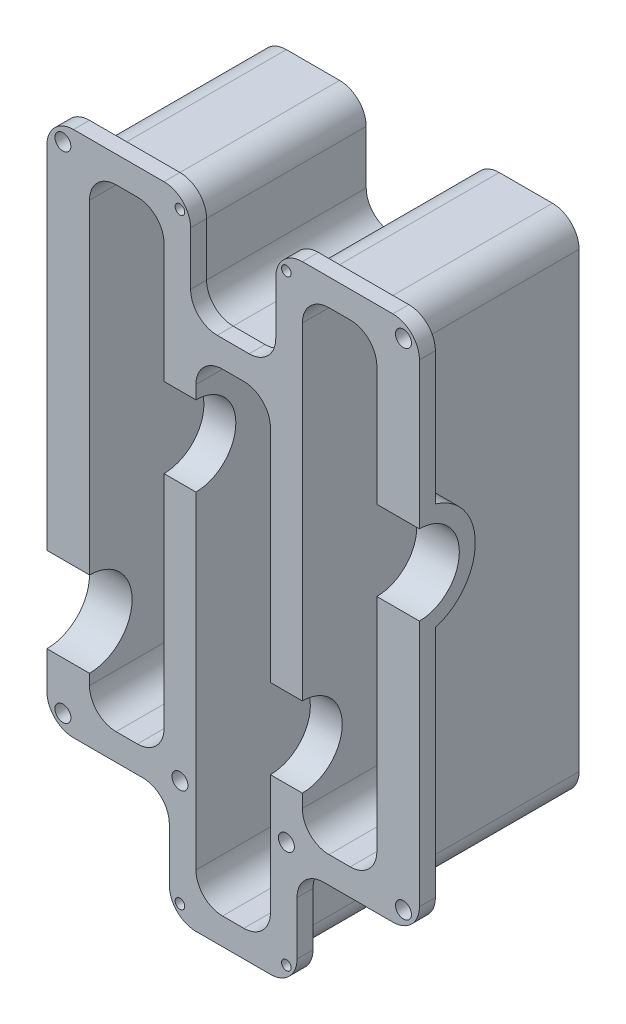
from build123d import *

# Parameters (mm, degrees)
SKETCH1_W           = 70
SKETCH1_H           = 119
BOSS_EXTRUDE1_DEPTH = 35
SKETCH2_R           = 8
CUT_EXTRUDE1_DEPTH  = 8
CUT_EXTRUDE2_DEPTH  = 32
SKETCH4_R           = 7.5
CUT_EXTRUDE3_DEPTH  = 8
SKETCH5_W           = 16
SKETCH5_H           = 20
SKETCH5_W_2         = 23
CUT_EXTRUDE4_DEPTH  = 36
CUT_EXTRUDE5_DEPTH  = 5
SKETCH7_W           = 18
SKETCH7_H           = 32
CUT_EXTRUDE6_DEPTH  = 2
SKETCH8_W           = 32
SKETCH8_H           = 22
CUT_EXTRUDE7_DEPTH  = 2
SKETCH9_W           = 22
SKETCH9_H           = 32
CUT_EXTRUDE8_DEPTH  = 2
SKETCH10_W          = 32
SKETCH10_H          = 18
CUT_EXTRUDE9_DEPTH  = 2
SKETCH11_W          = 25
SKETCH11_H          = 32
CUT_EXTRUDE10_DEPTH = 2
CUT_EXTRUDE11_DEPTH = 5
SKETCH14_W          = 22
SKETCH14_H          = 32
CUT_EXTRUDE12_DEPTH = 2
SKETCH16_W          = 32
SKETCH16_H          = 18
CUT_EXTRUDE13_DEPTH = 2
SKETCH17_W          = 18
SKETCH17_H          = 32
CUT_EXTRUDE14_DEPTH = 2
SKETCH18_W          = 32
SKETCH18_H          = 22
CUT_EXTRUDE15_DEPTH = 2
SKETCH19_W          = 20
SKETCH19_H          = 32
CUT_EXTRUDE16_DEPTH = 2
FILLET1_R           = 5
FILLET3_R           = 5
FILLET4_R           = 5
SKETCH20_R          = 1.5
CUT_EXTRUDE17_DEPTH = 10
SKETCH21_R          = 0.9
CUT_EXTRUDE18_DEPTH = 10
BOSS_EXTRUDE2_DEPTH = 6
BOSS_EXTRUDE3_DEPTH = 6


with BuildPart() as part:
    # Sketch1 → Boss-Extrude1 (new body)
    with BuildSketch(Plane.XY):
        Rectangle(SKETCH1_W, SKETCH1_H)
    extrude(amount=BOSS_EXTRUDE1_DEPTH)

    # Sketch2 → Cut-Extrude1 (cut)
    with BuildSketch(Plane.ZY.offset(35)):
        with Locations((35, -19.5)):
            Circle(SKETCH2_R)
    extrude(amount=-CUT_EXTRUDE1_DEPTH, mode=Mode.SUBTRACT)

    # Sketch3 → Cut-Extrude2 (cut)
    with BuildSketch(Plane.XY.offset(35)):
        Polygon((-27, 54.5), (-13, 54.5), (-13, 27), (-7, 27), (-7, 34.5), (7, 34.5), (7, -12), (13, -12), (13, 54.5), (27, 54.5), (27, -34.5), (13, -34.5), (13, -27), (7, -27), (7, -54.5), (-7, -54.5), (-7, 12), (-13, 12), (-13, -34.5), (-27, -34.5), align=None)
    extrude(amount=-CUT_EXTRUDE2_DEPTH, mode=Mode.SUBTRACT)

    # Sketch4 → Cut-Extrude3 (cut)
    with BuildSketch(Plane(origin=(35, 0, 0), x_dir=(0, 0, -1), z_dir=(1, 0, 0))):
        with Locations((-35, 19.5)):
            Circle(SKETCH4_R)
    extrude(amount=-CUT_EXTRUDE3_DEPTH, mode=Mode.SUBTRACT)

    # Sketch5 → Cut-Extrude4 (cut, through all)
    with BuildSketch(Plane.XY.offset(35)):
        with Locations((0, 49.5)):
            Rectangle(SKETCH5_W, SKETCH5_H)
        with Locations((-23.5, -49.5)):
            Rectangle(SKETCH5_W_2, SKETCH5_H)
        with Locations((23.5, -49.5)):
            Rectangle(SKETCH5_W_2, SKETCH5_H)
    extrude(amount=-CUT_EXTRUDE4_DEPTH, mode=Mode.SUBTRACT)

    # Sketch6 → Cut-Extrude5 (cut)
    with BuildSketch(Plane.ZY.offset(35)):
        with BuildLine():
            Line((32, 59.5), (0, 59.5))
            Line((0, 59.5), (0, -39.5))
            Line((0, -39.5), (32, -39.5))
            Line((32, -39.5), (32, -30.083005244))
            ThreePointArc((32, -30.083005244), (24, -19.5), (32, -8.916994756))
            Line((32, -8.916994756), (32, 59.5))
        make_face()
    extrude(amount=-CUT_EXTRUDE5_DEPTH, mode=Mode.SUBTRACT)

    # Sketch7 → Cut-Extrude6 (cut)
    with BuildSketch(Plane.XZ.offset(39.5)):
        with Locations((-21, 16)):
            Rectangle(SKETCH7_W, SKETCH7_H)
    extrude(amount=-CUT_EXTRUDE6_DEPTH, mode=Mode.SUBTRACT)

    # Sketch8 → Cut-Extrude7 (cut)
    with BuildSketch(Plane.ZY.offset(12)):
        with Locations((16, -48.5)):
            Rectangle(SKETCH8_W, SKETCH8_H)
    extrude(amount=-CUT_EXTRUDE7_DEPTH, mode=Mode.SUBTRACT)

    # Sketch9 → Cut-Extrude8 (cut)
    with BuildSketch(Plane.XZ.offset(59.5)):
        with Locations((1, 16)):
            Rectangle(SKETCH9_W, SKETCH9_H)
    extrude(amount=-CUT_EXTRUDE8_DEPTH, mode=Mode.SUBTRACT)

    # Sketch10 → Cut-Extrude9 (cut)
    with BuildSketch(Plane(origin=(12, 0, 0), x_dir=(0, 0, -1), z_dir=(1, 0, 0))):
        with Locations((-16, -48.5)):
            Rectangle(SKETCH10_W, SKETCH10_H)
    extrude(amount=-CUT_EXTRUDE9_DEPTH, mode=Mode.SUBTRACT)

    # Sketch11 → Cut-Extrude10 (cut)
    with BuildSketch(Plane.XZ.offset(39.5)):
        with Locations((22.5, 16)):
            Rectangle(SKETCH11_W, SKETCH11_H)
    extrude(amount=-CUT_EXTRUDE10_DEPTH, mode=Mode.SUBTRACT)

    # Sketch13 → Cut-Extrude11 (cut)
    with BuildSketch(Plane(origin=(35, 0, 0), x_dir=(0, 0, -1), z_dir=(1, 0, 0))):
        with BuildLine():
            Line((-32, 59.5), (0, 59.5))
            Line((0, 59.5), (0, -37.5))
            Line((0, -37.5), (-32, -37.5))
            Line((-32, -37.5), (-32, 9.437694101))
            ThreePointArc((-32, 9.437694101), (-24.5, 19.5), (-32, 29.562305899))
            Line((-32, 29.562305899), (-32, 59.5))
        make_face()
    extrude(amount=-CUT_EXTRUDE11_DEPTH, mode=Mode.SUBTRACT)

    # Sketch14 → Cut-Extrude12 (cut)
    with BuildSketch(Plane(origin=(0, 59.5, 0), x_dir=(1, 0, 0), z_dir=(0, 1, 0))):
        with Locations((19, -16)):
            Rectangle(SKETCH14_W, SKETCH14_H)
    extrude(amount=-CUT_EXTRUDE12_DEPTH, mode=Mode.SUBTRACT)

    # Sketch16 → Cut-Extrude13 (cut)
    with BuildSketch(Plane.ZY.offset(-8)):
        with Locations((16, 48.5)):
            Rectangle(SKETCH16_W, SKETCH16_H)
    extrude(amount=-CUT_EXTRUDE13_DEPTH, mode=Mode.SUBTRACT)

    # Sketch17 → Cut-Extrude14 (cut)
    with BuildSketch(Plane(origin=(0, 39.5, 0), x_dir=(1, 0, 0), z_dir=(0, 1, 0))):
        with Locations((1, -16)):
            Rectangle(SKETCH17_W, SKETCH17_H)
    extrude(amount=-CUT_EXTRUDE14_DEPTH, mode=Mode.SUBTRACT)

    # Sketch18 → Cut-Extrude15 (cut)
    with BuildSketch(Plane(origin=(-8, 0, 0), x_dir=(0, 0, -1), z_dir=(1, 0, 0))):
        with Locations((-16, 48.5)):
            Rectangle(SKETCH18_W, SKETCH18_H)
    extrude(amount=-CUT_EXTRUDE15_DEPTH, mode=Mode.SUBTRACT)

    # Sketch19 → Cut-Extrude16 (cut)
    with BuildSketch(Plane(origin=(0, 59.5, 0), x_dir=(1, 0, 0), z_dir=(0, 1, 0))):
        with Locations((-20, -16)):
            Rectangle(SKETCH19_W, SKETCH19_H)
    extrude(amount=-CUT_EXTRUDE16_DEPTH, mode=Mode.SUBTRACT)

    # Fillet1
    fillet1_edges = [part.edges().sort_by_distance(p)[0] for p in [
        (-27, -34.5, 19),
        (-27, 54.5, 19),
        (-13, 54.5, 19),
        (-7, 34.5, 19),
        (7, 34.5, 19),
        (13, 54.5, 19),
        (27, 54.5, 19),
        (27, -34.5, 19),
        (13, -34.5, 19),
        (7, -54.5, 19),
        (-7, -54.5, 19),
        (-13, -34.5, 19),
    ]]
    fillet(fillet1_edges, radius=FILLET1_R)

    # Fillet3
    fillet3_edges = [part.edges().sort_by_distance(p)[0] for p in [
        (-30, -37.5, 16),
        (-10, -37.5, 16),
        (-10, -57.5, 16),
        (10, -57.5, 16),
        (10, -37.5, 16),
        (30, -37.5, 16),
        (30, 57.5, 16),
        (10, 57.5, 16),
        (10, 37.5, 16),
        (-10, 37.5, 16),
        (-10, 57.5, 16),
        (-30, 57.5, 16),
    ]]
    fillet(fillet3_edges, radius=FILLET3_R)

    # Fillet4
    fillet4_edges = [part.edges().sort_by_distance(p)[0] for p in [
        (-35, -39.5, 33.5),
        (-12, -39.5, 33.5),
        (-12, -59.5, 33.5),
        (12, -59.5, 33.5),
        (12, -39.5, 33.5),
        (35, -39.5, 33.5),
        (8, 59.5, 33.5),
        (8, 39.5, 33.5),
        (-8, 39.5, 33.5),
        (-8, 59.5, 33.5),
        (-35, 59.5, 33.5),
        (35, 59.5, 33.5),
    ]]
    fillet(fillet4_edges, radius=FILLET4_R)

    # Sketch20 → Cut-Extrude17 (cut)
    with BuildSketch(Plane.XY.offset(35)):
        with Locations((-32, 56.5)):
            Circle(SKETCH20_R)
        with Locations((32, 56.5)):
            Circle(SKETCH20_R)
        with Locations((32, -36.5)):
            Circle(SKETCH20_R)
        with Locations((-32, -36.5)):
            Circle(SKETCH20_R)
        with Locations((-10, -36.5)):
            Circle(SKETCH20_R)
        with Locations((10, -36.5)):
            Circle(SKETCH20_R)
    extrude(amount=-CUT_EXTRUDE17_DEPTH, mode=Mode.SUBTRACT)

    # Sketch21 → Cut-Extrude18 (cut)
    with BuildSketch(Plane.XY.offset(35)):
        with Locations((-10, 56.5)):
            Circle(SKETCH21_R)
        with Locations((10, 56.5)):
            Circle(SKETCH21_R)
        with Locations((10, -56.5)):
            Circle(SKETCH21_R)
        with Locations((-10, -56.5)):
            Circle(SKETCH21_R)
    extrude(amount=-CUT_EXTRUDE18_DEPTH, mode=Mode.SUBTRACT)

    # Sketch22 → Boss-Extrude2 (add)
    with BuildSketch(Plane.ZY.offset(13)):
        with BuildLine():
            Line((35, 27), (3, 27))
            Line((3, 27), (3, 12))
            Line((3, 12), (35, 12))
            ThreePointArc((35, 12), (27.5, 19.5), (35, 27))
        make_face()
    extrude(amount=-BOSS_EXTRUDE2_DEPTH)

    # Sketch24 → Boss-Extrude3 (add)
    with BuildSketch(Plane.ZY.offset(-7)):
        with BuildLine():
            Line((35, -12), (3, -12))
            Line((3, -12), (3, -27))
            Line((3, -27), (35, -27))
            ThreePointArc((35, -27), (27.5, -19.5), (35, -12))
        make_face()
    extrude(amount=-BOSS_EXTRUDE3_DEPTH)


solid = part.part
